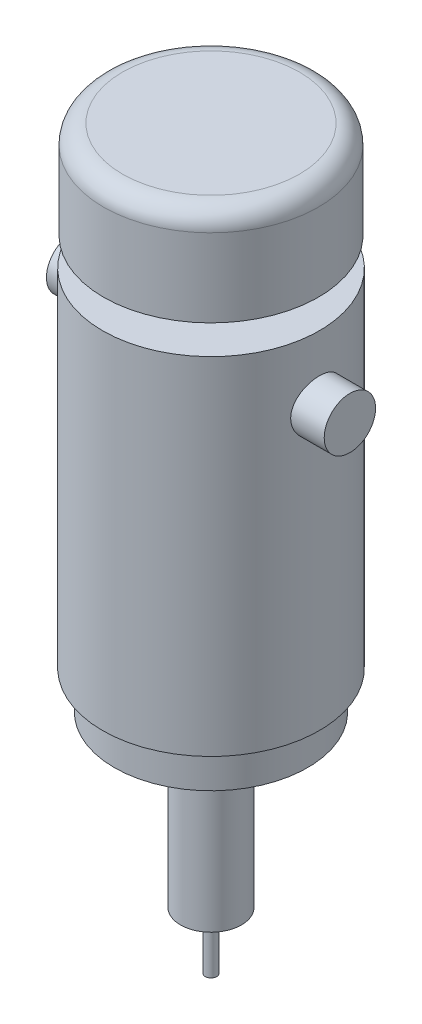
from build123d import *

# Parameters (mm, degrees)
SKETCH1_R           = 28.5
BOSS_EXTRUDE1_DEPTH = 45.5
SKETCH4_R           = 25.4
BOSS_EXTRUDE4_DEPTH = 10
SKETCH5_R           = 12.65
BOSS_EXTRUDE5_DEPTH = 2.5
SKETCH2_R           = 8
BOSS_EXTRUDE2_DEPTH = 42
SKETCH6_R           = 4
BOSS_EXTRUDE6_DEPTH = 33
SKETCH7_R           = 28.25
BOSS_EXTRUDE7_DEPTH = 25.5
FILLET1_R           = 5
SKETCH3_R           = 1.5
BOSS_EXTRUDE3_DEPTH = 15
SKETCH8_R           = 6.75
BOSS_EXTRUDE8_DEPTH = 36.5


with BuildPart() as part:
    # Sketch1 → Boss-Extrude1 (new body, symmetric)
    with BuildSketch(Plane(origin=(0, 0, 0), x_dir=(1, 0, 0), z_dir=(0, 1, 0))):
        Circle(SKETCH1_R)
    extrude(amount=BOSS_EXTRUDE1_DEPTH, both=True)

    # Sketch4 → Boss-Extrude4 (add)
    with BuildSketch(Plane.XZ.offset(45.5)):
        Circle(SKETCH4_R)
    extrude(amount=BOSS_EXTRUDE4_DEPTH)

    # Sketch5 → Boss-Extrude5 (add)
    with BuildSketch(Plane.XZ.offset(55.5)):
        Circle(SKETCH5_R)
    extrude(amount=BOSS_EXTRUDE5_DEPTH)

    # Sketch2 → Boss-Extrude2 (add)
    with BuildSketch(Plane.XZ.offset(58)):
        Circle(SKETCH2_R)
    extrude(amount=BOSS_EXTRUDE2_DEPTH)

    # Sketch6 → Boss-Extrude6 (add)
    with BuildSketch(Plane(origin=(0, 45.5, 0), x_dir=(1, 0, 0), z_dir=(0, 1, 0))):
        Circle(SKETCH6_R)
    extrude(amount=BOSS_EXTRUDE6_DEPTH)

    # Sketch7 → Boss-Extrude7 (add)
    with BuildSketch(Plane(origin=(0, 78.5, 0), x_dir=(1, 0, 0), z_dir=(0, 1, 0))):
        Circle(SKETCH7_R)
    extrude(amount=-BOSS_EXTRUDE7_DEPTH)

    # Fillet1
    fillet1_edges = [part.edges().sort_by_distance(p)[0] for p in [
        (-28.25, 78.5, 0),
    ]]
    fillet(fillet1_edges, radius=FILLET1_R)

    # Sketch3 → Boss-Extrude3 (add)
    with BuildSketch(Plane.XZ.offset(100)):
        Circle(SKETCH3_R)
    extrude(amount=BOSS_EXTRUDE3_DEPTH)

    # Sketch8 → Boss-Extrude8 (add, symmetric)
    with BuildSketch(Plane(origin=(0, 0, 0), x_dir=(0, 0, -1), z_dir=(1, 0, 0))):
        with Locations((0, 28.5)):
            Circle(SKETCH8_R)
    extrude(amount=BOSS_EXTRUDE8_DEPTH, both=True)


solid = part.part
